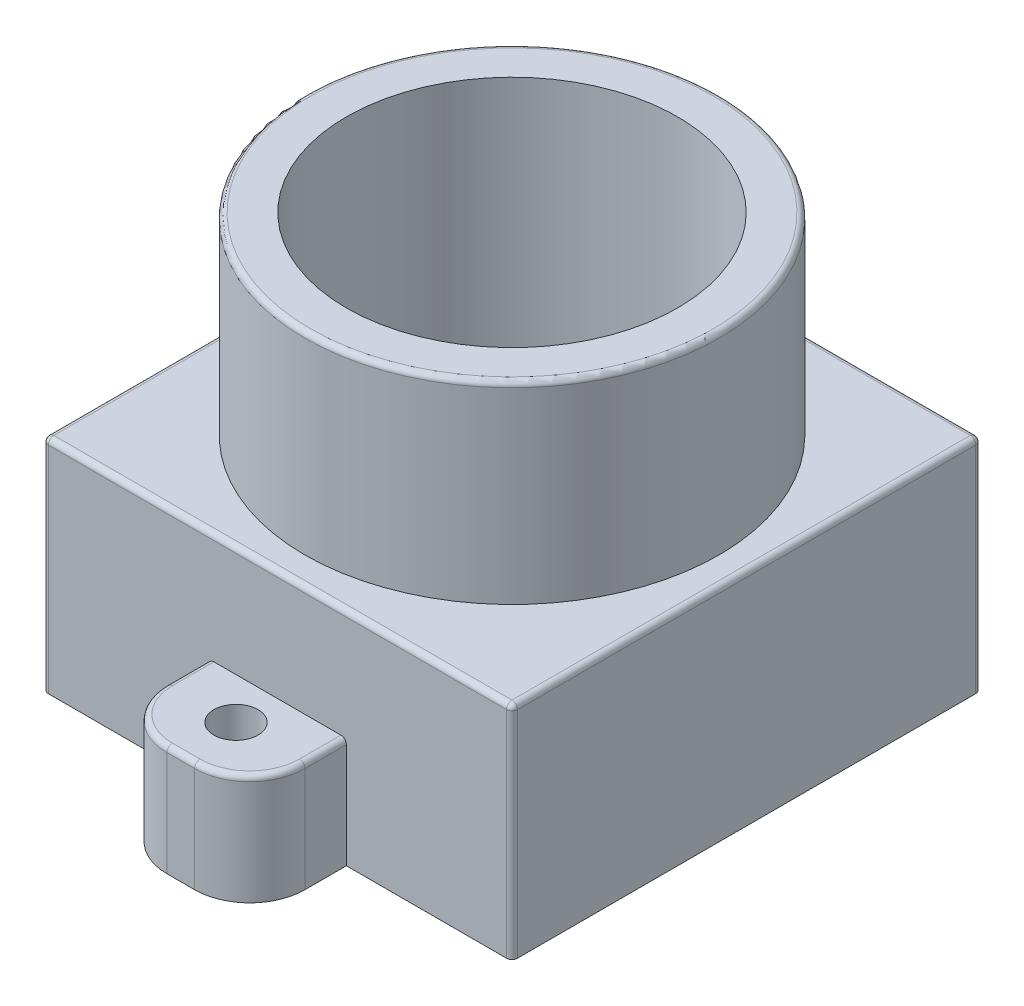
from build123d import *

# Parameters (mm, degrees)
SKETCH1_W             = 17
SKETCH1_H             = 17
BOSS_EXTRUDE1_DEPTH   = 8
SKETCH2_W             = 5
SKETCH2_H             = 4
BOSS_EXTRUDE2_DEPTH   = 3.5
SKETCH3_W             = 5
SKETCH3_H             = 4
BOSS_EXTRUDE3_DEPTH   = 3.5
M2X0_4_TAPPED_HOLE1_D = 1.6
FILLET1_R             = 2
SKETCH8_R             = 7.5
BOSS_EXTRUDE4_DEPTH   = 7
SKETCH9_R             = 6
CUT_EXTRUDE1_DEPTH    = 16
FILLET2_R             = 0.2


with BuildPart() as part:
    # Sketch1 → Boss-Extrude1 (new body)
    with BuildSketch(Plane(origin=(0, 0, 0), x_dir=(1, 0, 0), z_dir=(0, 1, 0))):
        Rectangle(SKETCH1_W, SKETCH1_H)
    extrude(amount=BOSS_EXTRUDE1_DEPTH)

    # Sketch2 → Boss-Extrude2 (add)
    with BuildSketch(Plane.XY.offset(8.5)):
        with Locations((0, 2)):
            Rectangle(SKETCH2_W, SKETCH2_H)
    extrude(amount=BOSS_EXTRUDE2_DEPTH)

    # Sketch3 → Boss-Extrude3 (add)
    with BuildSketch(Plane(origin=(0, 0, -8.5), x_dir=(-1, 0, 0), z_dir=(0, 0, -1))):
        with Locations((0, 2)):
            Rectangle(SKETCH3_W, SKETCH3_H)
    extrude(amount=BOSS_EXTRUDE3_DEPTH)

    # M2x0.4 Tapped Hole1 (through all)
    with Locations(Plane(origin=(0, 4, 0), x_dir=(1, 0, 0), z_dir=(0, 1, 0))):
        with Locations((0, -10), (0, 10)):
            Hole(M2X0_4_TAPPED_HOLE1_D / 2)

    # Fillet1
    fillet1_edges = [part.edges().sort_by_distance(p)[0] for p in [
        (-2.5, 2, 12),
        (2.5, 2, 12),
        (-2.5, 2, -12),
        (2.5, 2, -12),
    ]]
    fillet(fillet1_edges, radius=FILLET1_R)

    # Sketch8 → Boss-Extrude4 (add)
    with BuildSketch(Plane(origin=(0, 8, 0), x_dir=(1, 0, 0), z_dir=(0, 1, 0))):
        Circle(SKETCH8_R)
    extrude(amount=BOSS_EXTRUDE4_DEPTH)

    # Sketch9 → Cut-Extrude1 (cut, through all)
    with BuildSketch(Plane(origin=(0, 15, 0), x_dir=(1, 0, 0), z_dir=(0, 1, 0))):
        Circle(SKETCH9_R)
    extrude(amount=-CUT_EXTRUDE1_DEPTH, mode=Mode.SUBTRACT)

    # Fillet2
    fillet2_edges = [part.edges().sort_by_distance(p)[0] for p in [
        (-7.5, 15, 0),
        (8.5, 4, 8.5),
        (8.5, 4, -8.5),
        (-8.5, 4, 8.5),
        (-8.5, 4, -8.5),
        (2.5, 4, 9.25),
        (1.914213562, 4, 11.414213562),
        (-1.914213562, 4, 11.414213562),
        (-2.5, 4, 9.25),
        (0, 8, 8.5),
        (8.5, 8, 0),
        (-8.5, 8, 0),
        (0, 8, -8.5),
        (2.5, 4, -9.25),
        (1.914213562, 4, -11.414213562),
        (-1.914213562, 4, -11.414213562),
        (-2.5, 4, -9.25),
        (0, 4, 12),
        (0, 4, -12),
    ]]
    fillet(fillet2_edges, radius=FILLET2_R)


solid = part.part
